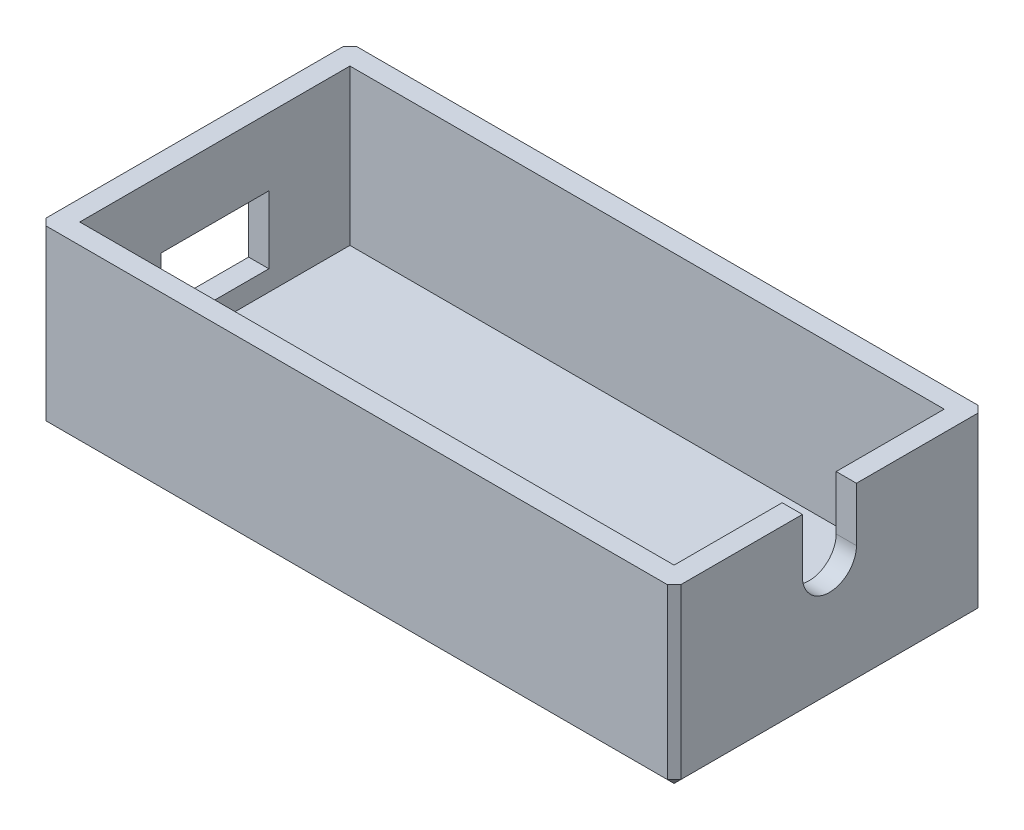
from build123d import *

# Parameters (mm, degrees)
SKETCH1_W           = 47
SKETCH1_H           = 23
SKETCH1_W_2         = 44
SKETCH1_H_2         = 20
BOSS_EXTRUDE1_DEPTH = 13
SKETCH2_W           = 44
SKETCH2_H           = 20
CUT_EXTRUDE1_DEPTH  = 11.5
SKETCH3_W           = 8
SKETCH3_H           = 5
CUT_EXTRUDE2_DEPTH  = 11.5
CUT_EXTRUDE3_DEPTH  = 11.5
CHAMFER1_SIZE       = 0.5


with BuildPart() as part:
    # Sketch1 → Boss-Extrude1 (new body)
    with BuildSketch(Plane(origin=(0, 0, 0), x_dir=(1, 0, 0), z_dir=(0, 1, 0))):
        with Locations((0.5, -3.291122715)):
            Rectangle(SKETCH1_W, SKETCH1_H)
        with Locations((0.5, -3.291122715)):
            Rectangle(SKETCH1_W_2, SKETCH1_H_2, mode=Mode.SUBTRACT)
        with Locations((0.5, -3.291122715)):
            Rectangle(SKETCH1_W_2, SKETCH1_H_2)
    extrude(amount=BOSS_EXTRUDE1_DEPTH)

    # Sketch2 → Cut-Extrude1 (cut)
    with BuildSketch(Plane(origin=(0, 13, 0), x_dir=(1, 0, 0), z_dir=(0, 1, 0))):
        with Locations((0.5, -3.291122715)):
            Rectangle(SKETCH2_W, SKETCH2_H)
    extrude(amount=-CUT_EXTRUDE1_DEPTH, mode=Mode.SUBTRACT)

    # Sketch3 → Cut-Extrude2 (cut)
    with BuildSketch(Plane(origin=(-21.5, 0, 0), x_dir=(0, 0, -1), z_dir=(1, 0, 0))):
        with Locations((-3.291122715, 5.5)):
            Rectangle(SKETCH3_W, SKETCH3_H)
    extrude(amount=-CUT_EXTRUDE2_DEPTH, mode=Mode.SUBTRACT)

    # Sketch4 → Cut-Extrude3 (cut)
    with BuildSketch(Plane.ZY.offset(-22.5)):
        with BuildLine():
            ThreePointArc((5.291122715, 9), (3.291122715, 11), (1.291122715, 9))
            Line((1.291122715, 9), (5.291122715, 9))
        make_face()
        with BuildLine():
            Line((5.291122715, 9), (1.291122715, 9))
            ThreePointArc((1.291122715, 9), (3.291122715, 7), (5.291122715, 9))
        make_face()
        with BuildLine():
            Line((5.291122715, 13), (1.291122715, 13))
            Line((1.291122715, 13), (1.291122715, 9))
            ThreePointArc((1.291122715, 9), (3.291122715, 11), (5.291122715, 9))
            Line((5.291122715, 9), (5.291122715, 13))
        make_face()
    extrude(amount=-CUT_EXTRUDE3_DEPTH, mode=Mode.SUBTRACT)

    # Chamfer1
    chamfer1_edges = [part.edges().sort_by_distance(p)[0] for p in [
        (0.5, 0, 14.791122715),
        (-23, 0, 3.291122715),
        (0.5, 0, -8.208877285),
        (24, 0, 3.291122715),
        (24, 6.5, 14.791122715),
        (-23, 6.5, 14.791122715),
        (-23, 6.5, -8.208877285),
        (24, 6.5, -8.208877285),
    ]]
    chamfer(chamfer1_edges, length=CHAMFER1_SIZE)


solid = part.part
